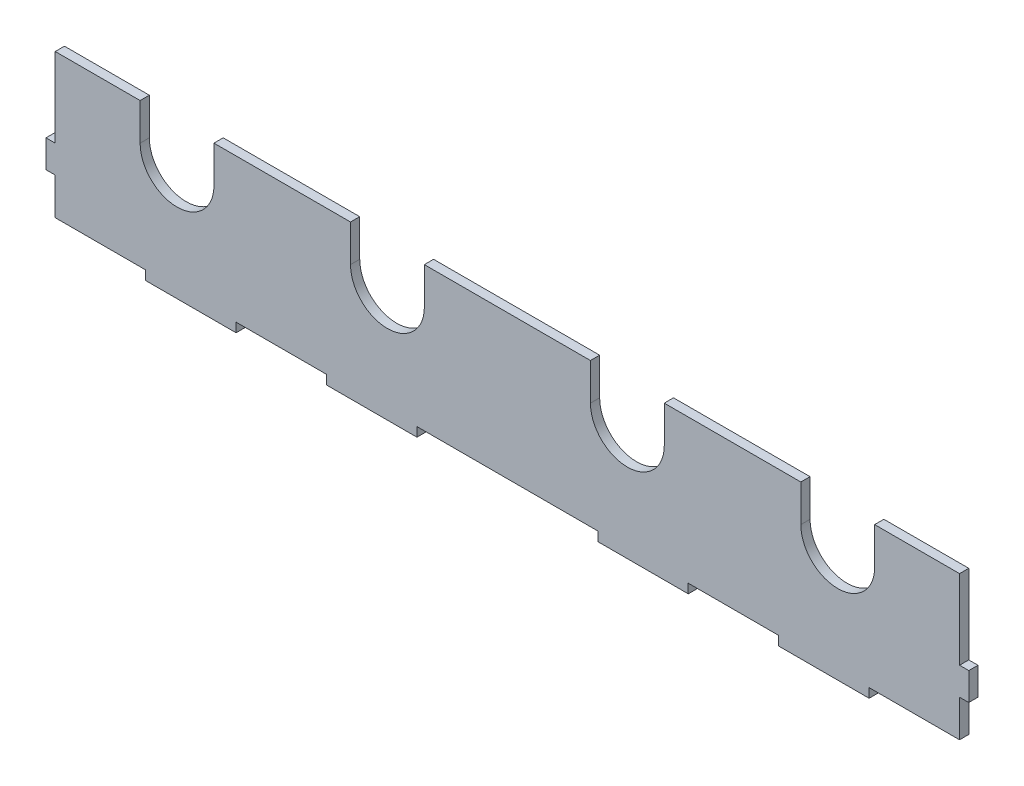
from build123d import *

# Parameters (mm, degrees)
BOSS_EXTRU_1_DEPTH = 5


with BuildPart() as part:
    # Esquisse1 → Boss.-Extru.1 (new body)
    with BuildSketch(Plane.XY):
        with BuildLine():
            Line((0, 40), (0, 83))
            Line((0, 83), (46, 83))
            Line((46, 83), (46, 63))
            ThreePointArc((46, 63), (66, 43), (86, 63))
            Line((86, 63), (86, 83))
            Line((86, 83), (160, 83))
            Line((160, 83), (160, 63))
            ThreePointArc((160, 63), (180, 43), (200, 63))
            Line((200, 63), (200, 83))
            Line((200, 83), (290, 83))
            Line((290, 83), (290, 63))
            ThreePointArc((290, 63), (310, 43), (330, 63))
            Line((330, 63), (330, 83))
            Line((330, 83), (404, 83))
            Line((404, 83), (404, 63))
            ThreePointArc((404, 63), (424, 43), (444, 63))
            Line((444, 63), (444, 83))
            Line((444, 83), (490, 83))
            Line((490, 83), (490, 40))
            Line((490, 40), (495, 40))
            Line((495, 40), (495, 25))
            Line((495, 25), (490, 25))
            Line((490, 25), (490, 5))
            Line((490, 5), (441, 5))
            Line((441, 5), (441, 0))
            Line((441, 0), (392, 0))
            Line((392, 0), (392, 5))
            Line((392, 5), (343, 5))
            Line((343, 5), (343, 0))
            Line((343, 0), (294, 0))
            Line((294, 0), (294, 5))
            Line((294, 5), (245, 5))
            Line((245, 5), (196, 5))
            Line((196, 5), (196, 0))
            Line((196, 0), (147, 0))
            Line((147, 0), (147, 5))
            Line((147, 5), (98, 5))
            Line((98, 5), (98, 0))
            Line((98, 0), (49, 0))
            Line((49, 0), (49, 5))
            Line((49, 5), (0, 5))
            Line((0, 5), (0, 25))
            Line((0, 25), (-5, 25))
            Line((-5, 25), (-5, 40))
            Line((-5, 40), (0, 40))
        make_face()
    extrude(amount=BOSS_EXTRU_1_DEPTH)


solid = part.part
